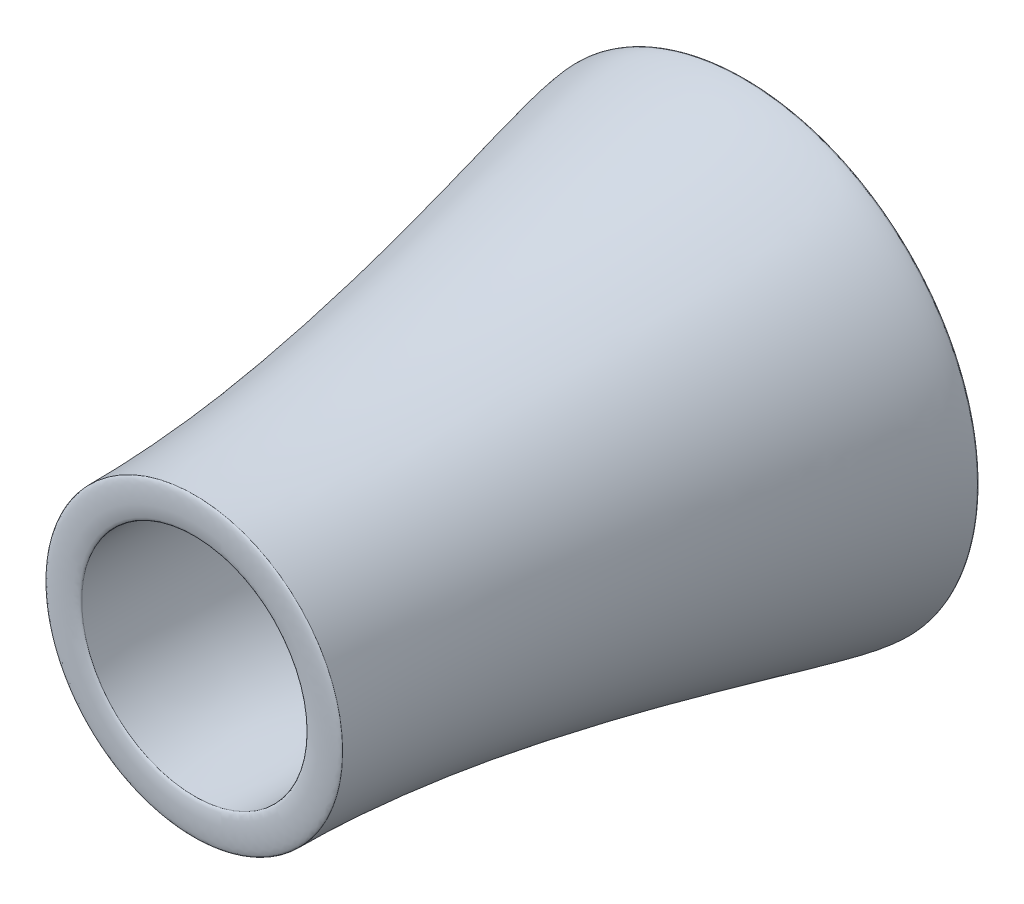
from build123d import *


with BuildPart() as part:
    # Sketch21 → Revolve2 (revolve)
    with BuildSketch(Plane(origin=(0, 0, 0), x_dir=(1, 0, 0), z_dir=(0, 1, 0))):
        with BuildLine():
            Line((-342.830536996, -1095.462493929), (-450.143329298, -1095.462493929))
            add(Edge.make_bspline(
                [(-711.609923736, 570.808492492), (-711.609923736, 445.424540116), (-450.143329298, -365.153373544), (-450.143329298, -1095.462493929)],
                knots=[0, 0, 0, 0, 1, 1, 1, 1], degree=3))
            Line((-711.609923736, 570.808492492), (-603.463057221, 570.808492492))
            add(Edge.make_bspline(
                [(-603.463057221, 570.808492492), (-603.463057221, 518.17273997), (-505.664095697, 359.371165984), (-484.160636642, 99.187151717), (-304.658098036, -485.273482821), (-342.830536996, -806.353873289), (-342.830536996, -1095.462493929)],
                knots=[0, 0, 0, 0, 0.158009172, 0.206506907, 0.484977351, 1, 1, 1, 1], degree=3))
        make_face()
    revolve(axis=Axis((0, 0, 99.684784321), (0, 0, -1)))


with BuildPart() as body_2:
    # Sketch22 → Revolve3 (revolve)
    with BuildSketch(Plane(origin=(0, 0, 0), x_dir=(1, 0, 0), z_dir=(0, 1, 0))):
        with BuildLine():
            Line((-711.609923736, 570.808492492), (-603.463057221, 570.808492492))
            add(Edge.make_bspline(
                [(-711.609923736, 570.808492492), (-711.609923736, 587.741825826), (-603.463057221, 587.741825826), (-603.463057221, 570.808492492)],
                knots=[0, 0, 0, 0, 1, 1, 1, 1], degree=3))
        make_face()
    revolve(axis=Axis((0, 0, 99.684784321), (0, 0, -1)))


with BuildPart() as body_3:
    # Sketch23 → Revolve4 (revolve)
    with BuildSketch(Plane(origin=(0, 0, 0), x_dir=(1, 0, 0), z_dir=(0, 1, 0))):
        with BuildLine():
            Line((-450.143329298, -1095.462493929), (-342.830536996, -1095.462493929))
            add(Edge.make_bspline(
                [(-450.143329298, -1095.462493929), (-450.143329298, -1108.162493929), (-342.830536996, -1108.162493929), (-342.830536996, -1095.462493929)],
                knots=[0, 0, 0, 0, 1, 1, 1, 1], degree=3))
        make_face()
    revolve(axis=Axis((0, 0, 1104.756830123), (0, 0, -1)))


solid = Compound([part.part, body_2.part, body_3.part])
